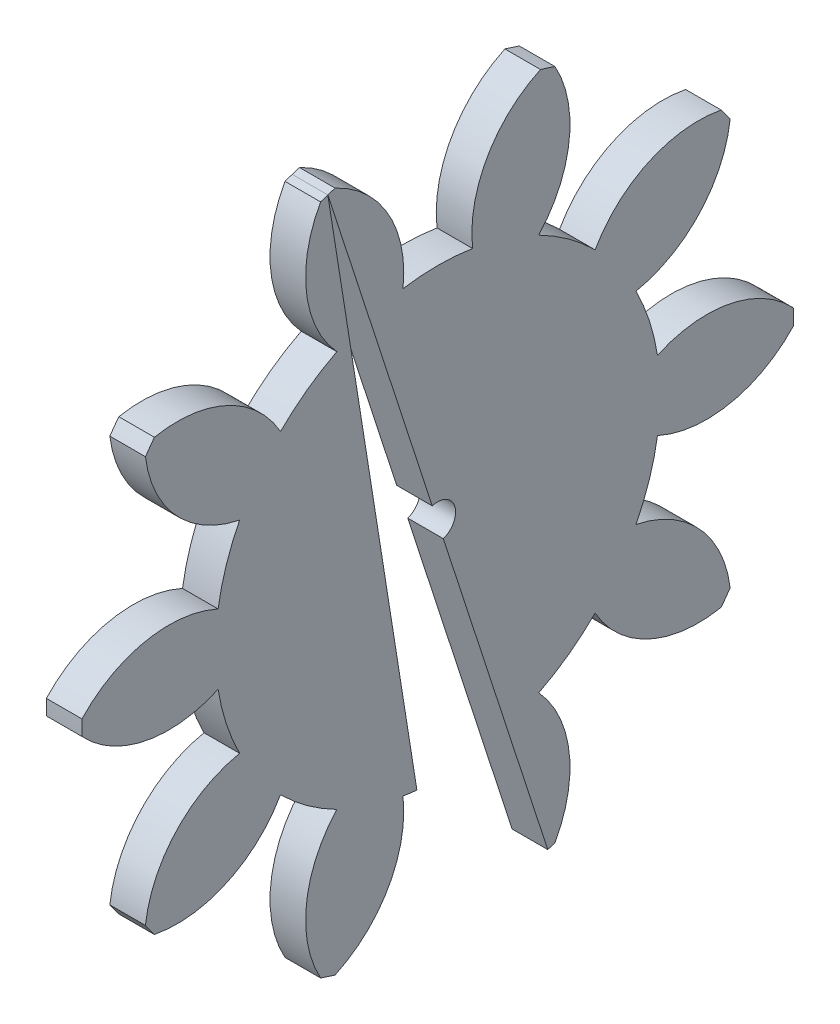
from build123d import *

# Parameters (mm, degrees)
BASPROSKE_W        = 3
BASPROSKE_H        = 30
TOOTHCUT_DEPTH     = 43.532340636
TEETHCUTS_COUNT    = 10
TEETHCUTS_ANGLE    = 324
BORSKE_R           = 1.5
BORE_DEPTH         = 50.0000508
CUT_EXTRUDE1_DEPTH = 10


with BuildPart() as part:
    # BasProSke → Base-Revolve (revolve)
    with BuildSketch(Plane(origin=(0, 0, 0), x_dir=(1, 0, 0), z_dir=(0, 1, 0)), mode=Mode.PRIVATE) as base_revolve_sk:
        with Locations((1.5, 15)):
            Rectangle(BASPROSKE_W, BASPROSKE_H)
    revolve(base_revolve_sk.sketch.rotate(Axis((-10, 0, 0), (1, 0, 0)), 180), axis=Axis((-10, 0, 0), (1, 0, 0)))

    # TooCutSke → ToothCut (cut, through all)
    with BuildSketch(Plane(origin=(0, 0, 0), x_dir=(0, 0, -1), z_dir=(1, 0, 0))):
        with BuildLine():
            ThreePointArc((2.93332476, 18.51811564), (0, 18.749), (-2.93332476, 18.51811564))
            ThreePointArc((-2.93332476, 18.51811564), (-4.155816835, 24.562157762), (-8.691330358, 28.739962104))
            ThreePointArc((-8.691330358, 28.739962104), (0, 30.0254), (8.691330358, 28.739962104))
            ThreePointArc((8.691330358, 28.739962104), (4.155816835, 24.562157762), (2.93332476, 18.51811564))
        make_face()
    toothcut = extrude(amount=TOOTHCUT_DEPTH, mode=Mode.SUBTRACT)

    # TeethCuts: ToothCut ×10 about axis
    teethcuts_axis = Axis((-10, 0, 0), (1, 0, 0))
    for i in range(1, TEETHCUTS_COUNT):
        add(toothcut.rotate(teethcuts_axis, i * TEETHCUTS_ANGLE / (TEETHCUTS_COUNT - 1)), mode=Mode.SUBTRACT)

    # BorSke → Bore (cut, symmetric)
    with BuildSketch(Plane(origin=(0, 0, 0), x_dir=(0, 0, -1), z_dir=(1, 0, 0))):
        with Locations(Location((0, 0, 0), (0, 0, 180))):
            Circle(BORSKE_R)
    extrude(amount=BORE_DEPTH, both=True, mode=Mode.SUBTRACT)

    # Sketch1 → Cut-Extrude1 (cut)
    with BuildSketch(Plane.ZY):
        Polygon((-9.270509831, -28.531695489), (9.270509831, 28.531695489), (-1.174030149, -37.108850883), align=None)
    extrude(amount=-CUT_EXTRUDE1_DEPTH, mode=Mode.SUBTRACT)


with BuildPart() as cut_extrude1_piece_1:
    # of the separate pieces the step leaves, piece 1, a body of its own (cut_extrude1_pieces)
    add(part.part.solids().sort_by_distance((0, 28.723914418, -8.656600978))[0])


with BuildPart() as cut_extrude1_piece_2:
    # of the separate pieces the step leaves, piece 2, a body of its own (cut_extrude1_pieces)
    add(part.part.solids().sort_by_distance((0, 28.326357299, 9.880155978))[0])


solid = Compound([cut_extrude1_piece_1.part, cut_extrude1_piece_2.part])
